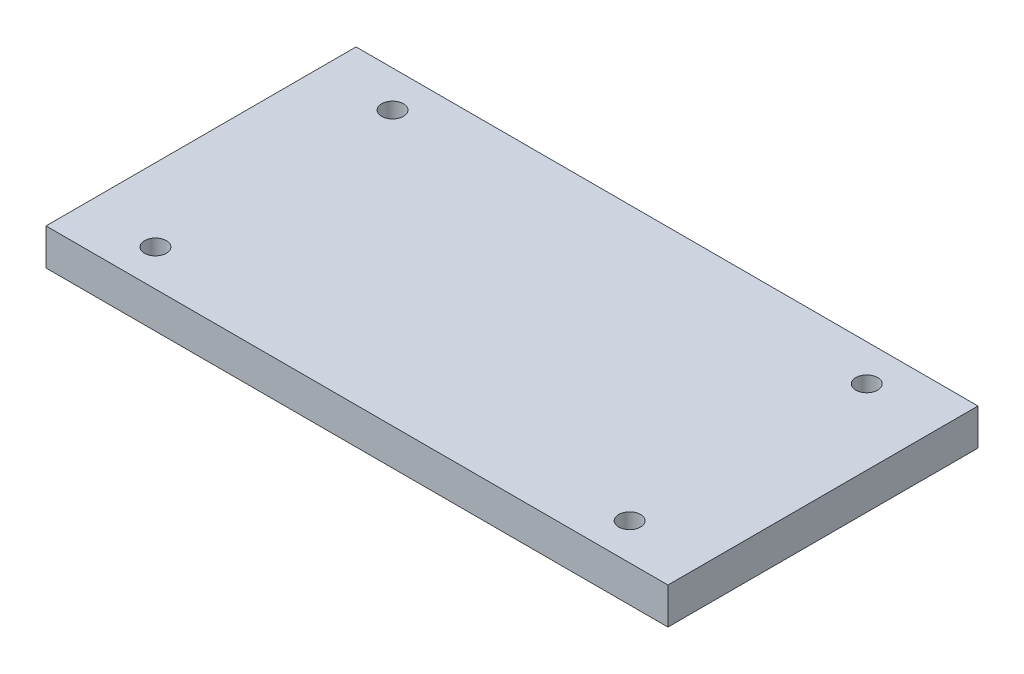
from build123d import *

# Parameters (mm, degrees)
SKETCH1_W           = 170.5
SKETCH1_H           = 85
SKETCH1_R           = 3
BOSS_EXTRUDE1_DEPTH = 10


with BuildPart() as part:
    # Sketch1 → Boss-Extrude1 (new body)
    with BuildSketch(Plane(origin=(0, 0, 0), x_dir=(1, 0, 0), z_dir=(0, 1, 0))):
        with Locations((85.25, 42.5)):
            Rectangle(SKETCH1_W, SKETCH1_H)
        with Locations((20, 10)):
            Circle(SKETCH1_R, mode=Mode.SUBTRACT)
        with Locations((150, 10)):
            Circle(SKETCH1_R, mode=Mode.SUBTRACT)
        with Locations((20, 75)):
            Circle(SKETCH1_R, mode=Mode.SUBTRACT)
        with Locations((150, 75)):
            Circle(SKETCH1_R, mode=Mode.SUBTRACT)
    extrude(amount=BOSS_EXTRUDE1_DEPTH)


solid = part.part
